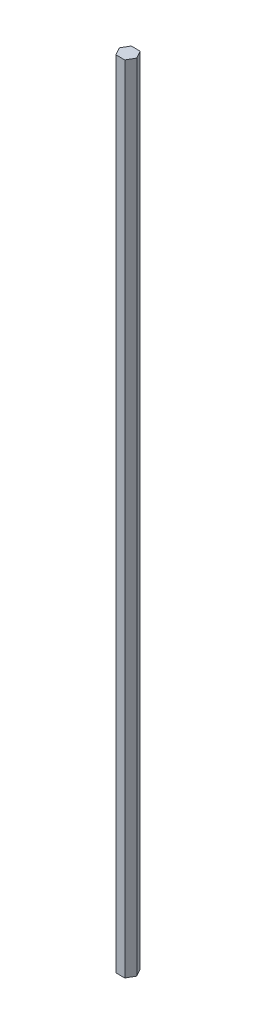
from build123d import *

# Parameters (mm, degrees)
BOSS_EXTRUDE1_DEPTH = 660.4


with BuildPart() as part:
    # Sketch1 → Boss-Extrude1 (new body)
    with BuildSketch(Plane(origin=(0, 0, 0), x_dir=(1, 0, 0), z_dir=(0, 1, 0))):
        Polygon((3.666174209, -6.35), (7.332348419, 0), (3.666174209, 6.35), (-3.666174209, 6.35), (-7.332348419, 0), (-3.666174209, -6.35), align=None)
    extrude(amount=BOSS_EXTRUDE1_DEPTH)


solid = part.part
